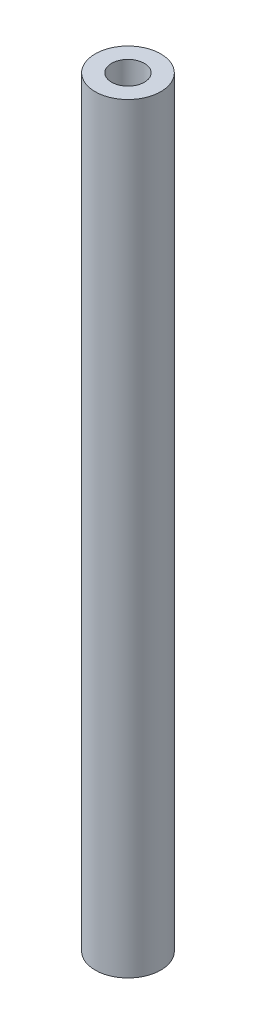
from build123d import *

# Parameters (mm, degrees)
SKETCH1_R           = 5
BOSS_EXTRUDE1_DEPTH = 116
SKETCH2_R           = 2.5
CUT_EXTRUDE1_DEPTH  = 10
SKETCH3_R           = 2.5
CUT_EXTRUDE2_DEPTH  = 10


with BuildPart() as part:
    # Sketch1 → Boss-Extrude1 (new body)
    with BuildSketch(Plane(origin=(0, 0, 0), x_dir=(1, 0, 0), z_dir=(0, 1, 0))):
        Circle(SKETCH1_R)
    extrude(amount=BOSS_EXTRUDE1_DEPTH)

    # Sketch2 → Cut-Extrude1 (cut)
    with BuildSketch(Plane(origin=(0, 116, 0), x_dir=(1, 0, 0), z_dir=(0, 1, 0))):
        Circle(SKETCH2_R)
    extrude(amount=-CUT_EXTRUDE1_DEPTH, mode=Mode.SUBTRACT)

    # Sketch3 → Cut-Extrude2 (cut)
    with BuildSketch(Plane.XZ):
        Circle(SKETCH3_R)
    extrude(amount=-CUT_EXTRUDE2_DEPTH, mode=Mode.SUBTRACT)


solid = part.part
